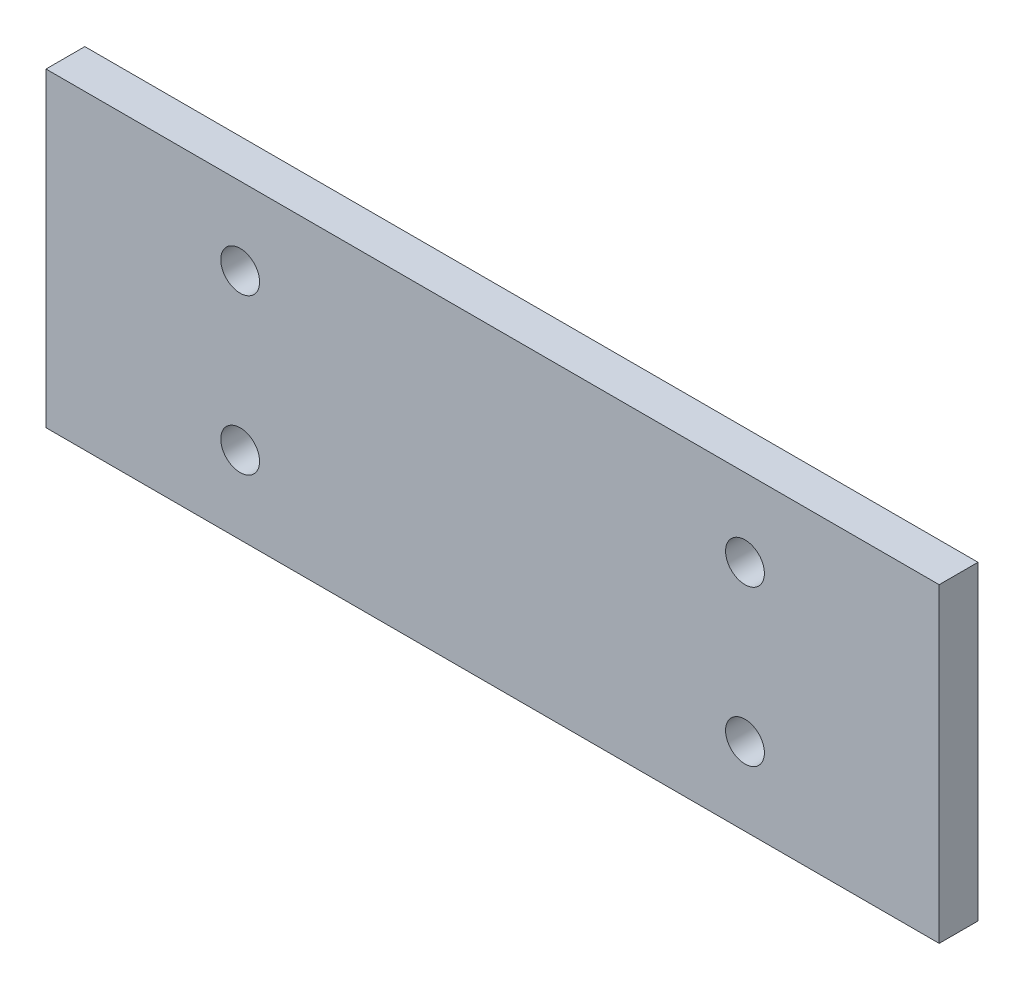
from build123d import *

# Parameters (mm, degrees)
SKETCH1_W           = 115
SKETCH1_H           = 40
SKETCH1_R           = 2.5
BOSS_EXTRUDE1_DEPTH = 5


with BuildPart() as part:
    # Sketch1 → Boss-Extrude1 (new body)
    with BuildSketch(Plane.XY):
        with Locations((57.5, 20)):
            Rectangle(SKETCH1_W, SKETCH1_H)
        with Locations((25, 30)):
            Circle(SKETCH1_R, mode=Mode.SUBTRACT)
        with Locations((25, 10)):
            Circle(SKETCH1_R, mode=Mode.SUBTRACT)
        with Locations((90, 10)):
            Circle(SKETCH1_R, mode=Mode.SUBTRACT)
        with Locations((90, 30)):
            Circle(SKETCH1_R, mode=Mode.SUBTRACT)
    extrude(amount=BOSS_EXTRUDE1_DEPTH)


solid = part.part
